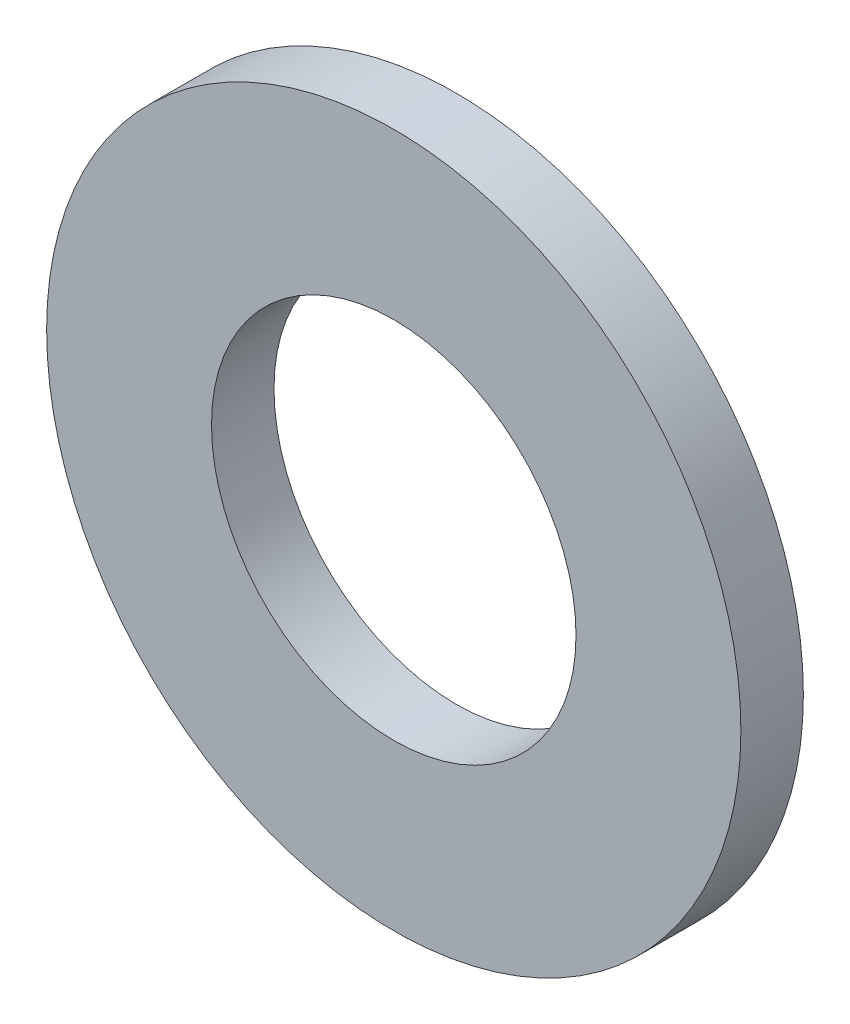
from build123d import *

# Parameters (mm, degrees)
SKETCH1_R      = 10
SKETCH1_R_2    = 5.25
EXTRUDE1_DEPTH = 1.8


with BuildPart() as part:
    # Sketch1 → Extrude1 (new body)
    with BuildSketch(Plane.XY):
        Circle(SKETCH1_R)
        Circle(SKETCH1_R_2, mode=Mode.SUBTRACT)
    extrude(amount=-EXTRUDE1_DEPTH)


solid = part.part
